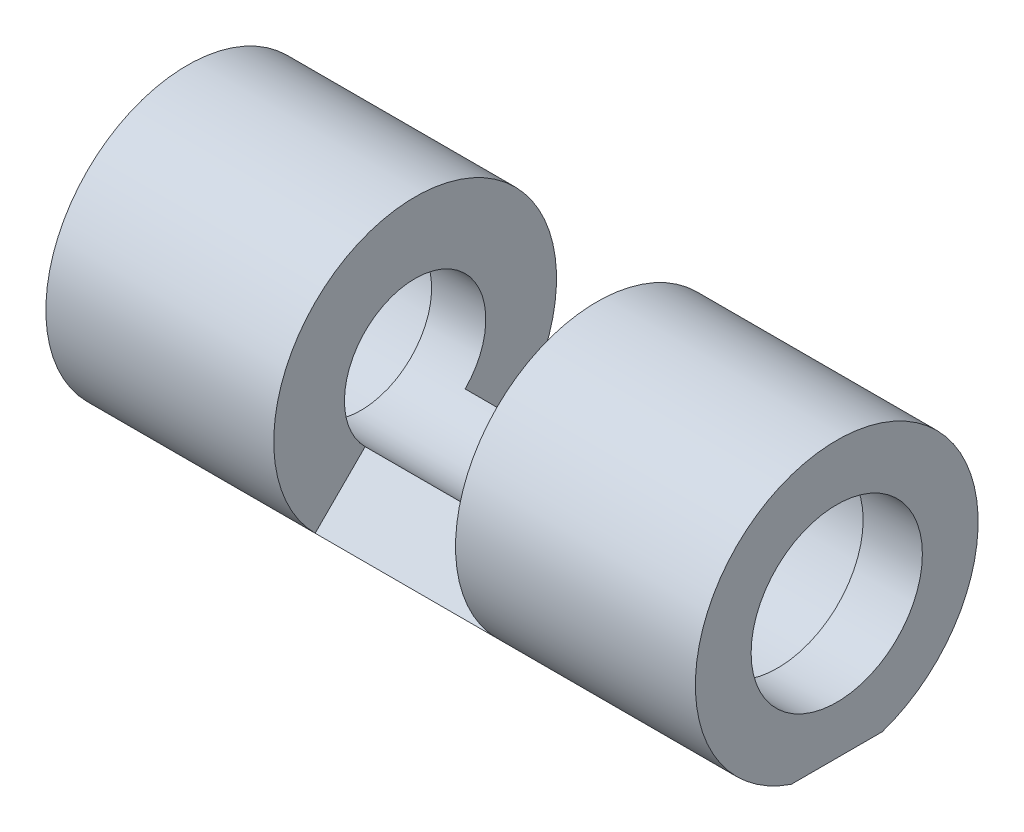
from build123d import *

# Parameters (mm, degrees)
SKETCH2_W               = 25.711141267
SKETCH2_H               = 16.935482271
CUT_REVOLVE1_ANGLE      = 270
SKETCH3_R               = 12.1123055
CUT_EXTRUDE1_DEPTH      = 12
CUT_EXTRUDE2_DEPTH      = 46.936892374
CUT_EXTRUDE2_DEPTH_BACK = 46.936892374


with BuildPart() as part:
    # Sketch1 → Revolve1 (revolve)
    with BuildSketch(Plane.XY):
        Polygon((-21.368212172, 15), (-21.368212172, 10), (21.368212172, 10), (21.368212172, 15), (37.560067367, 15), (37.560067367, 10), (45.936892374, 10), (45.936892374, 20), (-45.936892374, 20), (-45.936892374, 10), (-37.560067367, 10), (-37.560067367, 15), align=None)
    revolve(axis=Axis((-29.383970125, 0, 0), (1, 0, 0)))

    # Sketch2 → Cut-Revolve1 (revolve, symmetric, cut)
    with BuildSketch(Plane.XY) as cut_revolve1_sk:
        with Locations((-0.846360068, 17.320379596)):
            Rectangle(SKETCH2_W, SKETCH2_H)
    revolve(axis=Axis((-31.735702272, 0, 0), (1, 0, 0)), revolution_arc=CUT_REVOLVE1_ANGLE / 2, mode=Mode.SUBTRACT)
    revolve(cut_revolve1_sk.sketch, axis=Axis((-31.735702272, 0, 0), (-1, 0, 0)), revolution_arc=CUT_REVOLVE1_ANGLE / 2, mode=Mode.SUBTRACT)

    # Sketch3 → Cut-Extrude1 (cut)
    with BuildSketch(Plane.ZY.offset(45.936892374)):
        Circle(SKETCH3_R)
    cut_extrude1 = extrude(amount=-CUT_EXTRUDE1_DEPTH, mode=Mode.SUBTRACT)

    # Mirror1: Cut-Extrude1 across plane
    add(cut_extrude1.mirror(Plane(origin=(0, 0, 0), x_dir=(0, 0, 1), z_dir=(1, 0, 0))), mode=Mode.SUBTRACT)

    # Sketch4 → Cut-Extrude2 (cut, two sides)
    with BuildSketch(Plane(origin=(0, 0, 0), x_dir=(0, 0, -1), z_dir=(1, 0, 0))) as cut_extrude2_sk:
        Polygon((-23.278590176, -18.936948358), (32.516125961, -18.936948358), (-2.217008588, -46.464804995), align=None)
    extrude(amount=CUT_EXTRUDE2_DEPTH, mode=Mode.SUBTRACT)
    extrude(cut_extrude2_sk.sketch, amount=-CUT_EXTRUDE2_DEPTH_BACK, mode=Mode.SUBTRACT)


solid = part.part
